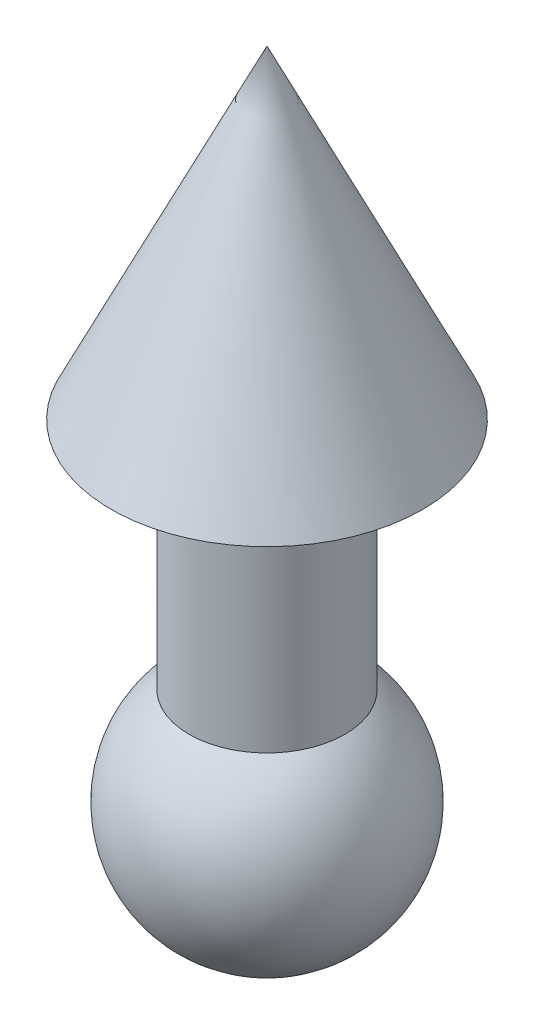
from build123d import *


with BuildPart() as part:
    # Sketch1 → Revolve1 (revolve)
    with BuildSketch(Plane.XY):
        with BuildLine():
            Line((5, 21.244997998), (5, 6.244997998))
            ThreePointArc((5, 6.244997998), (7.548509256, -2.649529771), (0, -8))
            Line((0, -8), (0, 42))
            Line((0, 42), (10, 21.244997998))
            Line((10, 21.244997998), (5, 21.244997998))
        make_face()
    revolve(axis=Axis((0, 42, 0), (0, -1, 0)))


solid = part.part
